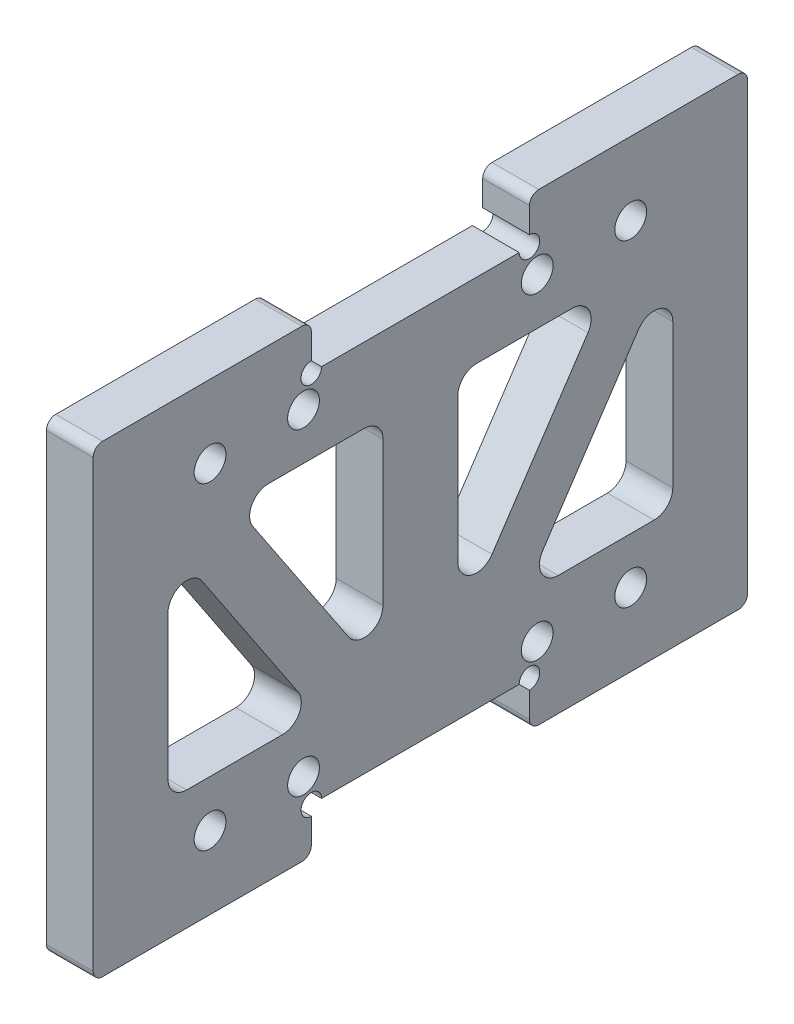
from build123d import *

# Parameters (mm, degrees)
SKETCH_1_W          = 70
SKETCH_1_H          = 40
EXTRUDE_1_DEPTH     = 5
CUT_EXTRUDE_1_DEPTH = 5
FILLET_1_R          = 2
SKETCH_3_W          = 23.333333333
SKETCH_3_H          = 4.8
EXTRUDE_2_DEPTH     = 5
FILLET_2_R          = 1
SKETCH_4_R          = 1.1
CUT_EXTRUDE_2_DEPTH = 5
HOLE_WIZARD_M3_1_D  = 3.4


with BuildPart() as part:
    # 草图1 → 凸台-拉伸1 (new body)
    with BuildSketch(Plane(origin=(0, 0, 0), x_dir=(0, 0, -1), z_dir=(1, 0, 0))):
        with Locations((35, 20)):
            Rectangle(SKETCH_1_W, SKETCH_1_H)
    extrude(amount=EXTRUDE_1_DEPTH)

    # 草图2 → 切除-拉伸1 (cut)
    with BuildSketch(Plane(origin=(5, 0, 0), x_dir=(0, 0, -1), z_dir=(1, 0, 0))):
        Polygon((8, 8), (24, 8), (8, 32), align=None)
        Polygon((31, 32), (31, 8), (15, 32), align=None)
        Polygon((39, 32), (39, 8), (55, 32), align=None)
        Polygon((62, 8), (62, 32), (46, 8), align=None)
    extrude(amount=-CUT_EXTRUDE_1_DEPTH, mode=Mode.SUBTRACT)

    # 圆角1
    fillet_1_edges = [part.edges().sort_by_distance(p)[0] for p in [
        (2.5, 32, -31),
        (2.5, 8, -31),
        (2.5, 32, -15),
        (2.5, 8, -39),
        (2.5, 32, -39),
        (2.5, 32, -55),
        (2.5, 32, -62),
        (2.5, 8, -62),
        (2.5, 8, -46),
        (2.5, 8, -8),
        (2.5, 32, -8),
        (2.5, 8, -24),
    ]]
    fillet(fillet_1_edges, radius=FILLET_1_R)

    # 草图3 → 凸台-拉伸2 (add)
    with BuildSketch(Plane(origin=(5, 0, 0), x_dir=(0, 0, -1), z_dir=(1, 0, 0))):
        with Locations((11.666666667, 42.4)):
            Rectangle(SKETCH_3_W, SKETCH_3_H)
        with Locations((58.333333334, 42.4)):
            Rectangle(SKETCH_3_W, SKETCH_3_H)
        with Locations((58.333333334, -2.4)):
            Rectangle(SKETCH_3_W, SKETCH_3_H)
        with Locations((11.666666667, -2.4)):
            Rectangle(SKETCH_3_W, SKETCH_3_H)
    extrude(amount=-EXTRUDE_2_DEPTH)

    # 圆角2
    fillet_2_edges = [part.edges().sort_by_distance(p)[0] for p in [
        (2.5, 44.8, 0),
        (2.5, 44.8, -23.333333333),
        (2.5, 44.8, -70),
        (2.5, 44.8, -46.666666667),
        (2.5, -4.8, -23.333333333),
        (2.5, -4.8, 0),
        (2.5, -4.8, -70),
        (2.5, -4.8, -46.666666667),
    ]]
    fillet(fillet_2_edges, radius=FILLET_2_R)

    # 草图4 → 切除-拉伸2 (cut)
    with BuildSketch(Plane(origin=(5, 0, 0), x_dir=(0, 0, -1), z_dir=(1, 0, 0))):
        with Locations((23.333333333, 40)):
            Circle(SKETCH_4_R)
        with Locations((46.666666667, 40)):
            Circle(SKETCH_4_R)
        with Locations((46.666666667, 0)):
            Circle(SKETCH_4_R)
        with Locations((23.333333333, 0)):
            Circle(SKETCH_4_R)
    extrude(amount=-CUT_EXTRUDE_2_DEPTH, mode=Mode.SUBTRACT)

    # M3 间隙孔1 (through all)
    with Locations(Plane(origin=(5, 0, 0), x_dir=(0, 0, -1), z_dir=(1, 0, 0))):
        with Locations((57.5, 37), (47.5, 37), (57.5, 3), (47.5, 3), (22.5, 3), (12.5, 3), (22.5, 37), (12.5, 37)):
            Hole(HOLE_WIZARD_M3_1_D / 2)


solid = part.part
